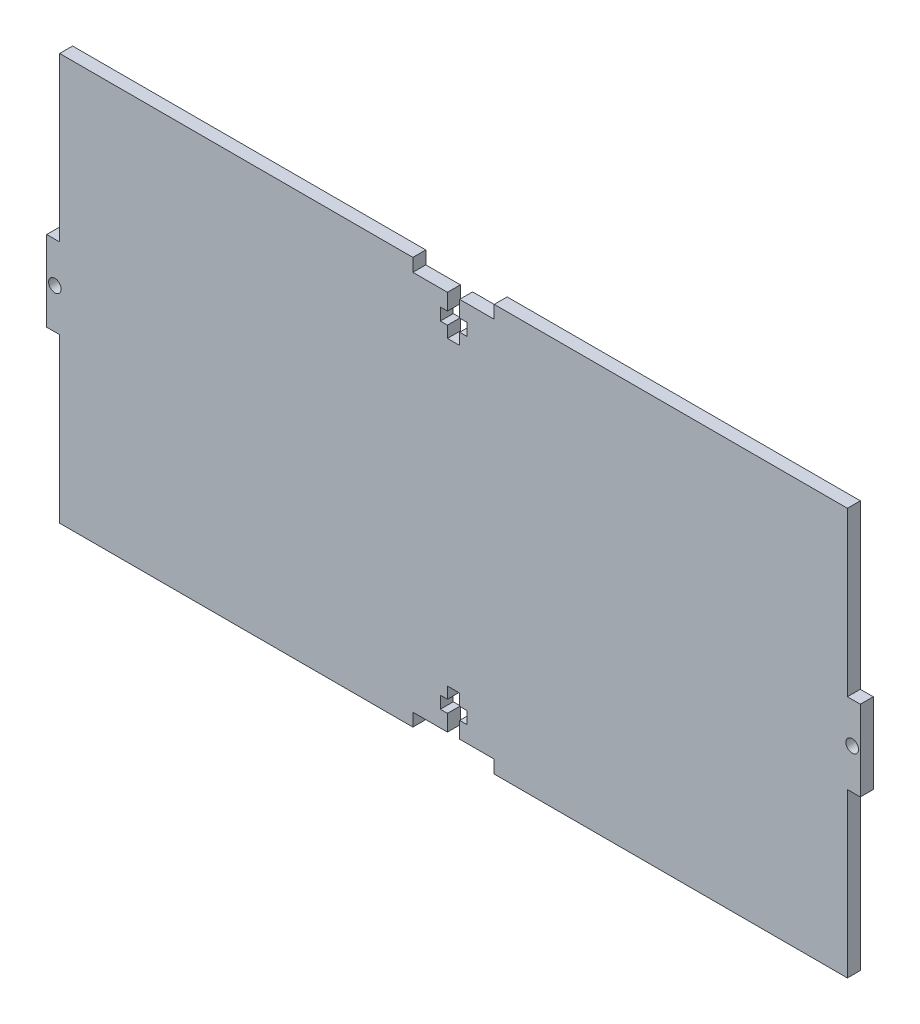
from build123d import *

# Parameters (mm, degrees)
SKETCH1_W           = 200
SKETCH1_H           = 100
BOSS_EXTRUDE2_DEPTH = 3.18
SKETCH2_R           = 1.55
SKETCH2_W           = 3.18
SKETCH2_H           = 40.125
CUT_EXTRUDE1_DEPTH  = 4.18


with BuildPart() as part:
    # Sketch1 → Boss-Extrude2 (new body)
    with BuildSketch(Plane.XY):
        Rectangle(SKETCH1_W, SKETCH1_H)
    extrude(amount=BOSS_EXTRUDE2_DEPTH)

    # Sketch2 → Cut-Extrude1 (cut, through all)
    with BuildSketch(Plane.XY.offset(3.18)):
        with Locations((-98, 0)):
            Circle(SKETCH2_R)
        Polygon((-10, 50), (-10, 46.82), (-1.5, 46.82), (-1.5, 42.82), (-3.25, 42.82), (-3.25, 39.82), (-1.5, 39.82), (-1.5, 37), (1.5, 37), (1.5, 39.82), (3.25, 39.82), (3.25, 42.82), (1.5, 42.82), (1.5, 46.82), (10, 46.82), (10, 50), align=None)
        with Locations((-98.41, 29.9375)):
            Rectangle(SKETCH2_W, SKETCH2_H)
        with Locations((-98.41, -29.9375)):
            Rectangle(SKETCH2_W, SKETCH2_H)
    cut_extrude1 = extrude(amount=-CUT_EXTRUDE1_DEPTH, mode=Mode.SUBTRACT)

    # Mirror1: Cut-Extrude1 across plane
    add(cut_extrude1.mirror(Plane.ZX), mode=Mode.SUBTRACT)

    # Mirror2: Cut-Extrude1 across plane
    add(cut_extrude1.mirror(Plane(origin=(0, 0, 0), x_dir=(0, 0, 1), z_dir=(1, 0, 0))), mode=Mode.SUBTRACT)


solid = part.part
